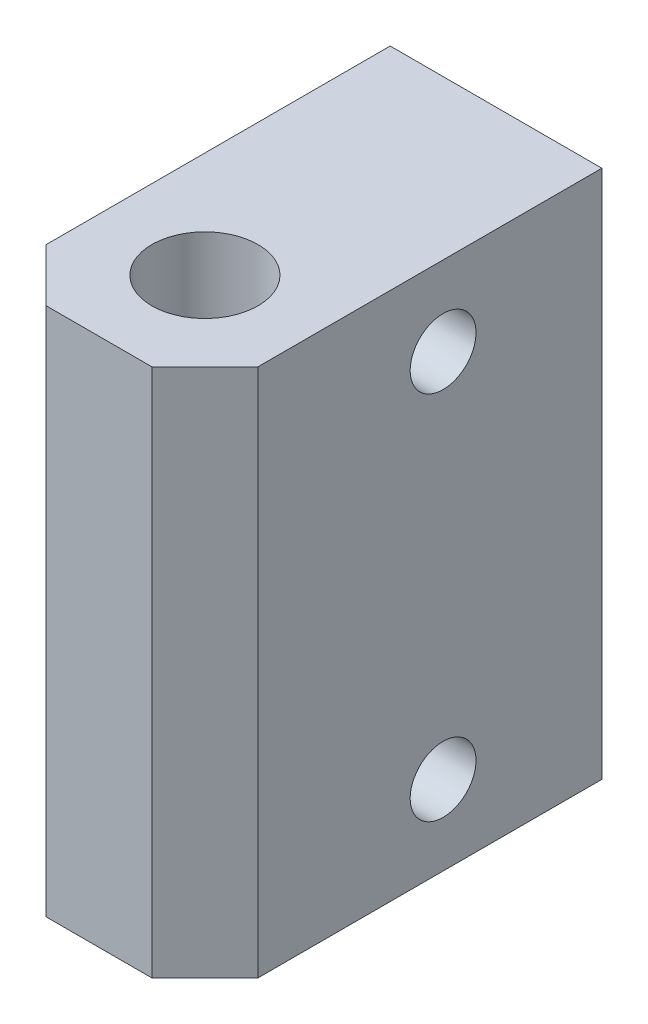
from build123d import *

# Parameters (mm, degrees)
SKETCH1_W                    = 16
SKETCH1_H                    = 30
BOSS_EXTRUDE1_DEPTH          = 40
O_0_316_DIAMETER_HOLE1_D     = 8.0264
O_0_316_DIAMETER_HOLE1_DEPTH = 15
O_0_316_DIAMETER_HOLE1_TIP   = 2.411373836
F_10_CLEARANCE_HOLE1_D       = 4.9784
CHAMFER1_SIZE                = 4


with BuildPart() as part:
    # Sketch1 → Boss-Extrude1 (new body)
    with BuildSketch(Plane(origin=(0, 0, 0), x_dir=(1, 0, 0), z_dir=(0, 1, 0))):
        with Locations((0, 7)):
            Rectangle(SKETCH1_W, SKETCH1_H)
    extrude(amount=BOSS_EXTRUDE1_DEPTH)

    # O (0.316) Diameter Hole1
    with Locations(Plane(origin=(0, 40, 0), x_dir=(1, 0, 0), z_dir=(0, 1, 0))):
        with Locations((0, 0)):
            Hole(O_0_316_DIAMETER_HOLE1_D / 2, depth=O_0_316_DIAMETER_HOLE1_DEPTH)
            with Locations((0, 0, -(O_0_316_DIAMETER_HOLE1_DEPTH + O_0_316_DIAMETER_HOLE1_TIP / 2))):  # 118° drill point
                Cone(0, O_0_316_DIAMETER_HOLE1_D / 2, O_0_316_DIAMETER_HOLE1_TIP, mode=Mode.SUBTRACT)

    # #10 Clearance Hole1 (through all)
    with Locations(Plane.ZY.offset(8)):
        with Locations((-10, 34), (-10, 6)):
            Hole(F_10_CLEARANCE_HOLE1_D / 2)

    # Chamfer1
    chamfer1_edges = [part.edges().sort_by_distance(p)[0] for p in [
        (8, 20, 8),
        (-8, 20, 8),
    ]]
    chamfer(chamfer1_edges, length=CHAMFER1_SIZE)


solid = part.part
